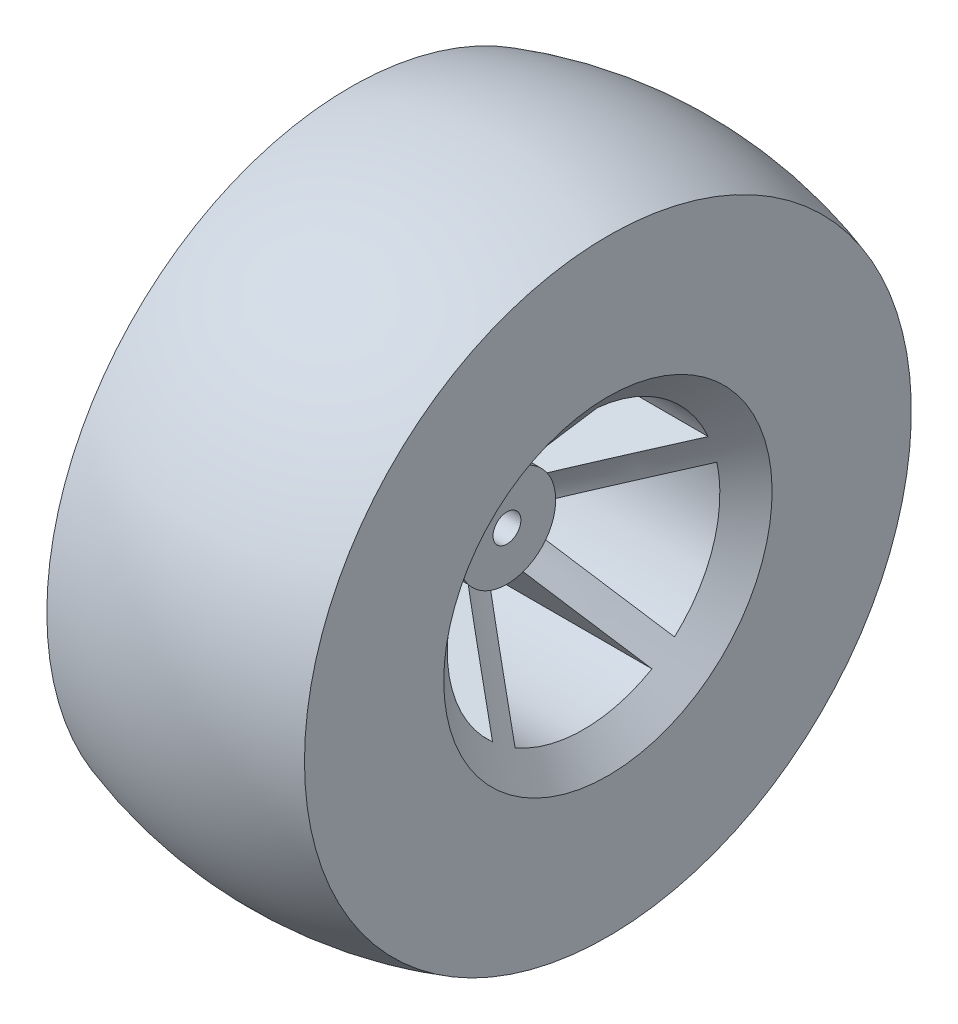
from build123d import *

# Parameters (mm, degrees)
CUT_EXTRUDE1_DEPTH      = 19.5000001
CUT_EXTRUDE1_DEPTH_BACK = 19.5000001


with BuildPart() as part:
    # Sketch1 → Revolve1 (revolve)
    with BuildSketch(Plane(origin=(0, 0, 0), x_dir=(1, 0, 0), z_dir=(0, 1, 0))):
        with BuildLine():
            Line((18.5, -43.576702778), (18.5, -23.576702778))
            Line((18.5, -23.576702778), (4, -7))
            Line((4, -7), (4, -2))
            Line((4, -2), (0, -2))
            Line((0, -2), (0, -46.5))
            ThreePointArc((0, -46.5), (9.364769974, -45.764669773), (18.5, -43.576702778))
        make_face()
    revolve(axis=Axis((-21.521301372, 0, 0), (1, 0, 0)))

    # Mirror1: part across plane


with BuildPart() as part_1:
    add(part.part)
    add(part.part.mirror(Plane(origin=(0, 0, 2), x_dir=(0, 0, 1), z_dir=(-1, 0, 0))))

    # Sketch2 → Cut-Extrude1 (cut, two sides)
    with BuildSketch(Plane(origin=(0, 0, 0), x_dir=(0, 0, -1), z_dir=(1, 0, 0))) as cut_extrude1_sk:
        with BuildLine():
            ThreePointArc((-5.761847074, 3.975062049), (-4.114496766, 5.663118961), (-2, 6.708203932))
            Line((-2, 6.708203932), (-2, 19.474272558))
            ThreePointArc((-2, 19.474272558), (-11.506897181, 15.837885241), (-17.903099827, 7.919994206))
            Line((-17.903099827, 7.919994206), (-5.761847074, 3.975062049))
        make_face()
        with BuildLine():
            Line((2, 19.474272558), (2, 6.708203932))
            ThreePointArc((2, 6.708203932), (4.114496766, 5.663118961), (5.761847074, 3.975062049))
            Line((5.761847074, 3.975062049), (17.903099827, 7.919994206))
            ThreePointArc((17.903099827, 7.919994206), (11.506897181, 15.837885241), (2, 19.474272558))
        make_face()
        with BuildLine():
            Line((-13.064724197, -14.579446948), (-5.56101733, -4.251480479))
            ThreePointArc((-5.56101733, -4.251480479), (-6.657395614, -2.163118961), (-6.997915051, 0.170835984))
            Line((-6.997915051, 0.170835984), (-19.139167805, 4.115768141))
            ThreePointArc((-19.139167805, 4.115768141), (-18.618550745, -6.049533852), (-13.064724197, -14.579446948))
        make_face()
        with BuildLine():
            Line((19.139167805, 4.115768141), (6.997915051, 0.170835984))
            ThreePointArc((6.997915051, 0.170835984), (6.999478743, 0.085424353), (7, 0))
            ThreePointArc((7, 0), (6.630502293, -2.244201271), (5.56101733, -4.251480479))
            Line((5.56101733, -4.251480479), (13.064724197, -14.579446948))
            ThreePointArc((13.064724197, -14.579446948), (17.874723972, -7.983829569), (19.576702778, 0))
            ThreePointArc((19.576702778, 0), (19.467011727, 2.069479659), (19.139167805, 4.115768141))
        make_face()
        with BuildLine():
            Line((9.82865622, -16.930587957), (2.324949352, -6.602621488))
            ThreePointArc((2.324949352, -6.602621488), (0, -7), (-2.324949352, -6.602621488))
            Line((-2.324949352, -6.602621488), (-9.82865622, -16.930587957))
            ThreePointArc((-9.82865622, -16.930587957), (0, -19.576702778), (9.82865622, -16.930587957))
        make_face()
    extrude(amount=CUT_EXTRUDE1_DEPTH, mode=Mode.SUBTRACT)
    extrude(cut_extrude1_sk.sketch, amount=-CUT_EXTRUDE1_DEPTH_BACK, mode=Mode.SUBTRACT)


solid = part_1.part
